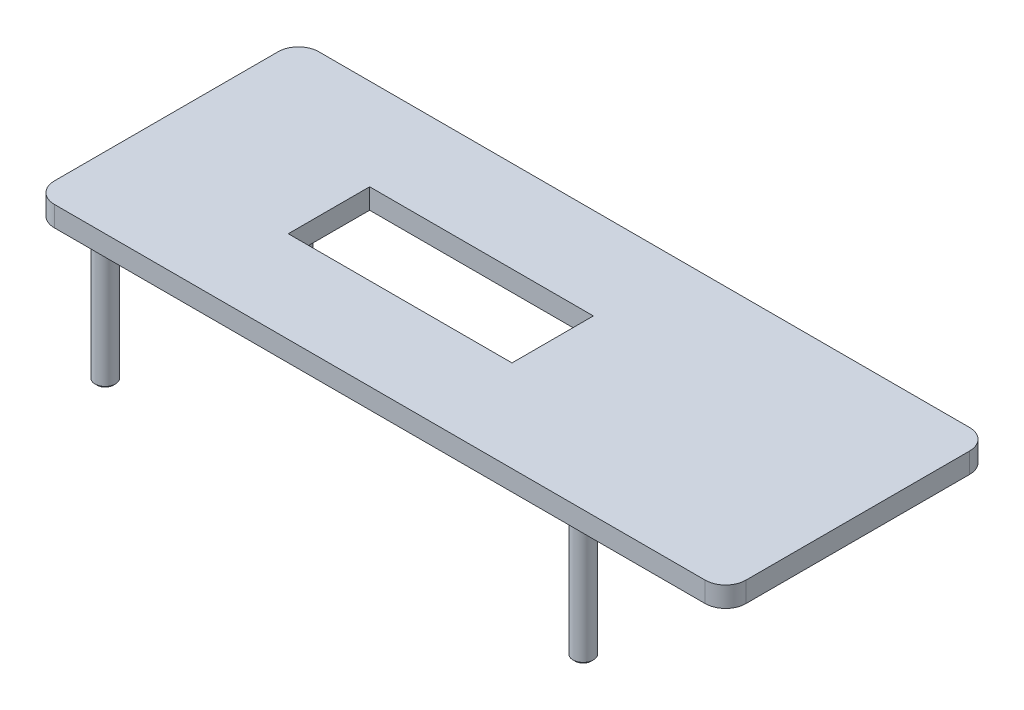
from build123d import *

# Parameters (mm, degrees)
BOSS_EXTRUDE1_DEPTH     = 1
SKETCH2_R               = 0.5
BOSS_EXTRUDE2_DEPTH     = 7
SKETCH4_W               = 11
SKETCH4_H               = 4
CUT_EXTRUDE1_DEPTH      = 1
CUT_EXTRUDE1_DEPTH_BACK = 9
CHAMFER2_SIZE           = 0.1


with BuildPart() as part:
    # Sketch1 → Boss-Extrude1 (new body)
    with BuildSketch(Plane(origin=(0, 0, 0), x_dir=(1, 0, 0), z_dir=(0, 1, 0))):
        with BuildLine():
            Line((-16, -6.5), (16, -6.5))
            ThreePointArc((16, -6.5), (16.707106781, -6.207106781), (17, -5.5))
            Line((17, -5.5), (17, 5.5))
            ThreePointArc((17, 5.5), (16.707106781, 6.207106781), (16, 6.5))
            Line((16, 6.5), (-16, 6.5))
            ThreePointArc((-16, 6.5), (-16.707106781, 6.207106781), (-17, 5.5))
            Line((-17, 5.5), (-17, -5.5))
            ThreePointArc((-17, -5.5), (-16.707106781, -6.207106781), (-16, -6.5))
        make_face()
    extrude(amount=BOSS_EXTRUDE1_DEPTH)

    # Sketch2 → Boss-Extrude2 (add)
    with BuildSketch(Plane.XZ):
        with Locations((-15.25, 4.75)):
            Circle(SKETCH2_R)
        with Locations((-15.25, -4.75)):
            Circle(SKETCH2_R)
        with Locations((8.25, -4.75)):
            Circle(SKETCH2_R)
        with Locations((8.25, 4.75)):
            Circle(SKETCH2_R)
    extrude(amount=BOSS_EXTRUDE2_DEPTH)

    # Sketch4 → Cut-Extrude1 (cut, two sides)
    with BuildSketch(Plane(origin=(0, 1, 0), x_dir=(1, 0, 0), z_dir=(0, 1, 0))) as cut_extrude1_sk:
        with Locations((-3.5, 0)):
            Rectangle(SKETCH4_W, SKETCH4_H)
    extrude(amount=CUT_EXTRUDE1_DEPTH, mode=Mode.SUBTRACT)
    extrude(cut_extrude1_sk.sketch, amount=-CUT_EXTRUDE1_DEPTH_BACK, mode=Mode.SUBTRACT)

    # Chamfer2
    chamfer2_edges = [part.edges().sort_by_distance(p)[0] for p in [
        (-15.75, -7, 4.75),
        (7.75, -7, 4.75),
        (7.75, -7, -4.75),
        (-15.75, -7, -4.75),
    ]]
    chamfer(chamfer2_edges, length=CHAMFER2_SIZE)


solid = part.part
